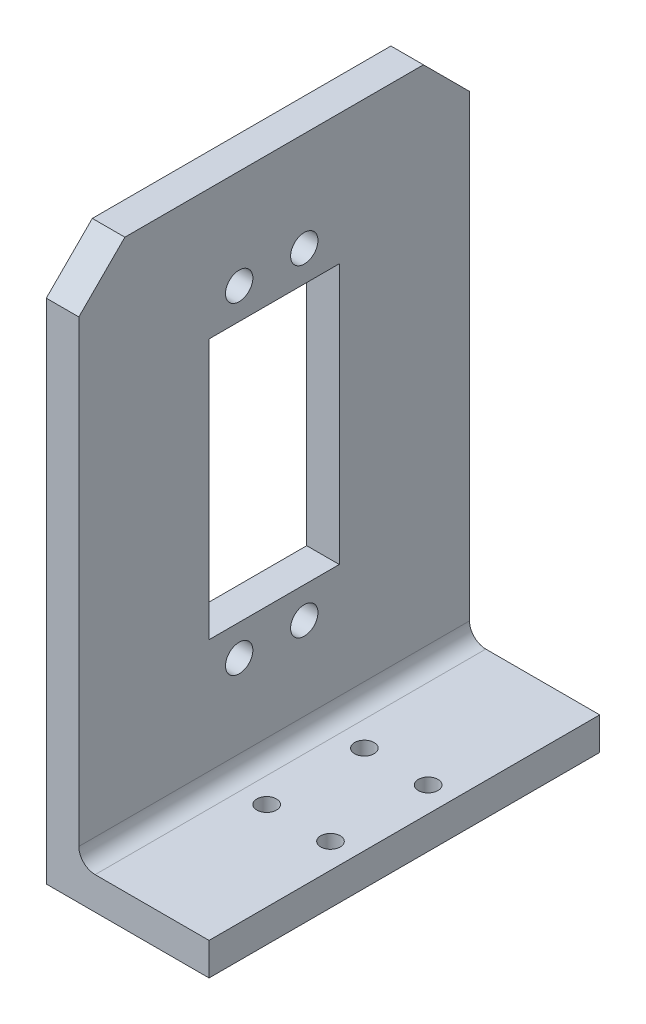
from build123d import *

# Parameters (mm, degrees)
SKETCH1_W             = 25
SKETCH1_H             = 60
BOSS_EXTRUDE1_DEPTH   = 5
SKETCH8_W             = 5
SKETCH8_H             = 60
BOSS_EXTRUDE2_DEPTH   = 80
SKETCH9_R             = 2.1
SKETCH9_W             = 20
SKETCH9_H             = 40
CUT_EXTRUDE1_DEPTH    = 5
CUT_EXTRUDE2_REACH    = 7
FILLET1_R             = 2.5
F_3_0MM_DOWEL_HOLE1_D = 3


with BuildPart() as part:
    # Sketch1 → Boss-Extrude1 (new body)
    with BuildSketch(Plane(origin=(0, 0, 0), x_dir=(1, 0, 0), z_dir=(0, 1, 0))):
        Rectangle(SKETCH1_W, SKETCH1_H)
    extrude(amount=BOSS_EXTRUDE1_DEPTH)

    # Sketch8 → Boss-Extrude2 (add)
    with BuildSketch(Plane(origin=(0, 5, 0), x_dir=(1, 0, 0), z_dir=(0, 1, 0))):
        with Locations((-10, 0)):
            Rectangle(SKETCH8_W, SKETCH8_H)
    extrude(amount=BOSS_EXTRUDE2_DEPTH)

    # Sketch9 → Cut-Extrude1 (cut)
    with BuildSketch(Plane(origin=(-7.5, 0, 0), x_dir=(0, 0, -1), z_dir=(1, 0, 0))):
        with Locations((-5.37452771, 69.75)):
            Circle(SKETCH9_R)
        with Locations((4.62547229, 69.75)):
            Circle(SKETCH9_R)
        with Locations((-5.37452771, 20.25)):
            Circle(SKETCH9_R)
        with Locations((4.62547229, 20.25)):
            Circle(SKETCH9_R)
        with Locations((0, 45)):
            Rectangle(SKETCH9_W, SKETCH9_H)
    extrude(amount=-CUT_EXTRUDE1_DEPTH, mode=Mode.SUBTRACT)

    # Sketch10 → Cut-Extrude2 (cut, up to next)
    with BuildSketch(Plane(origin=(-7.5, 0, 0), x_dir=(0, 0, -1), z_dir=(1, 0, 0)), mode=Mode.PRIVATE) as cut_extrude2_sk1:
        Polygon((-22.928932188, 85), (-30, 77.928932188), (-30, 85), align=None)
    cut_extrude2_tool1 = extrude(cut_extrude2_sk1.sketch, amount=-CUT_EXTRUDE2_REACH, mode=Mode.PRIVATE) & part.part
    add(cut_extrude2_tool1.solids().sort_by_distance((-7.5, 82.642977, 27.642977))[0], mode=Mode.SUBTRACT)
    # Sketch10 → Cut-Extrude2 (cut, up to next)
    with BuildSketch(Plane(origin=(-7.5, 0, 0), x_dir=(0, 0, -1), z_dir=(1, 0, 0)), mode=Mode.PRIVATE) as cut_extrude2_sk2:
        Polygon((22.928932188, 85), (30, 77.928932188), (30, 85), align=None)
    cut_extrude2_tool2 = extrude(cut_extrude2_sk2.sketch, amount=-CUT_EXTRUDE2_REACH, mode=Mode.PRIVATE) & part.part
    add(cut_extrude2_tool2.solids().sort_by_distance((-7.5, 82.642977, -27.642977))[0], mode=Mode.SUBTRACT)

    # Fillet1
    fillet1_edges = [part.edges().sort_by_distance(p)[0] for p in [
        (-7.5, 5, 0),
    ]]
    fillet(fillet1_edges, radius=FILLET1_R)

    # Ø3.0mm Dowel Hole1 (through all)
    with Locations(Plane(origin=(0, 5, 0), x_dir=(1, 0, 0), z_dir=(0, 1, 0))):
        with Locations((-1.15, 7.5), (-1.15, -7.5)):
            f_3_0mm_dowel_hole1 = Hole(F_3_0MM_DOWEL_HOLE1_D / 2)

    # Mirror1: Ø3.0mm Dowel Hole1 across plane
    add(f_3_0mm_dowel_hole1.mirror(Plane(origin=(3.75, 0, 0), x_dir=(0, 0, 1), z_dir=(1, 0, 0))), mode=Mode.SUBTRACT)


solid = part.part
